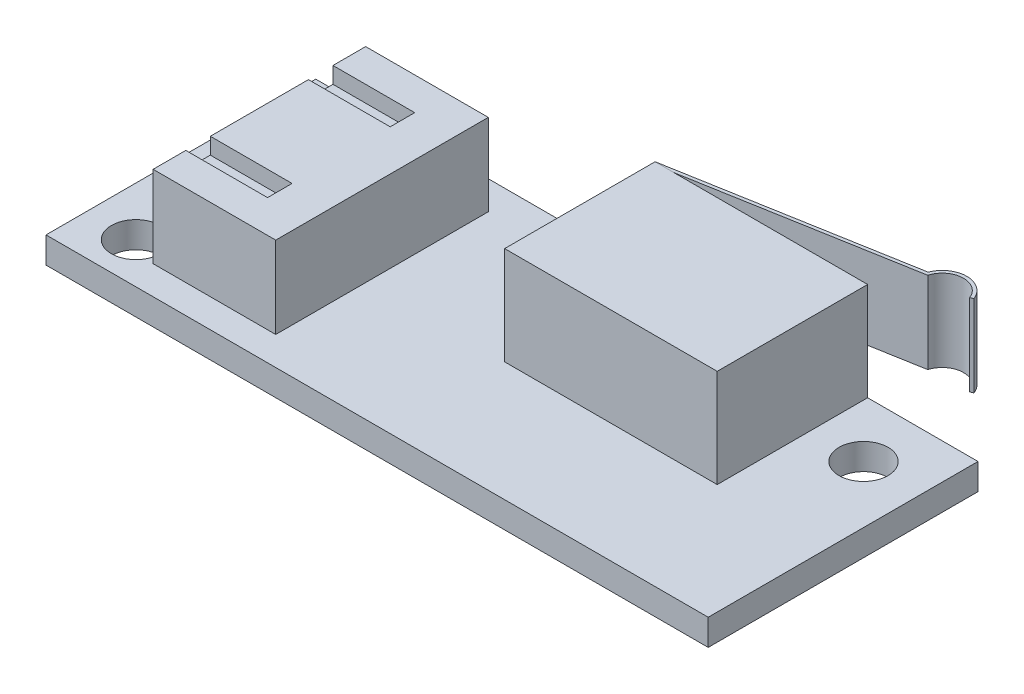
from build123d import *

# Parameters (mm, degrees)
SKETCH1_W           = 40.5
SKETCH1_H           = 16.5
SKETCH1_R           = 1.5
BOSS_EXTRUDE1_DEPTH = 1.6
SKETCH2_W           = 13
SKETCH2_H           = 9.2
BOSS_EXTRUDE2_DEPTH = 6
SKETCH3_W           = 7.5
SKETCH3_H           = 13
BOSS_EXTRUDE3_DEPTH = 5
SKETCH4_W           = 5
SKETCH4_H           = 1.5
CUT_EXTRUDE1_DEPTH  = 1
EXTRUDE_THIN1_DEPTH = 5


with BuildPart() as part:
    # Sketch1 → Boss-Extrude1 (new body)
    with BuildSketch(Plane(origin=(0, 0, 0), x_dir=(1, 0, 0), z_dir=(0, 1, 0))):
        Rectangle(SKETCH1_W, SKETCH1_H)
        with Locations((-17.25, -5.75)):
            Circle(SKETCH1_R, mode=Mode.SUBTRACT)
        with Locations((-17.25, 4.75)):
            Circle(SKETCH1_R, mode=Mode.SUBTRACT)
        with Locations((-2.25, 4.75)):
            Circle(SKETCH1_R, mode=Mode.SUBTRACT)
        with Locations((16.75, 4.75)):
            Circle(SKETCH1_R, mode=Mode.SUBTRACT)
    extrude(amount=BOSS_EXTRUDE1_DEPTH)


with BuildPart() as body_2:
    # Sketch2 → Boss-Extrude2 (new body)
    with BuildSketch(Plane(origin=(0, 1.6, 0), x_dir=(1, 0, 0), z_dir=(0, 1, 0))):
        with Locations((7, 3.65)):
            Rectangle(SKETCH2_W, SKETCH2_H)
    extrude(amount=BOSS_EXTRUDE2_DEPTH)


with BuildPart() as body_3:
    # Sketch3 → Boss-Extrude3 (new body)
    with BuildSketch(Plane(origin=(0, 1.6, 0), x_dir=(1, 0, 0), z_dir=(0, 1, 0))):
        with Locations((-11.7, 0)):
            Rectangle(SKETCH3_W, SKETCH3_H)
    extrude(amount=BOSS_EXTRUDE3_DEPTH)

    # Sketch4 → Cut-Extrude1 (cut)
    with BuildSketch(Plane(origin=(0, 6.6, 0), x_dir=(1, 0, 0), z_dir=(0, 1, 0))):
        with Locations((-12.95, 3.75)):
            Rectangle(SKETCH4_W, SKETCH4_H)
        with Locations((-12.95, -3.75)):
            Rectangle(SKETCH4_W, SKETCH4_H)
    extrude(amount=-CUT_EXTRUDE1_DEPTH, mode=Mode.SUBTRACT)


with BuildPart() as body_4:
    # Sketch5 → Extrude-Thin1 (new body)
    with BuildSketch(Plane(origin=(0, 7.6, 0), x_dir=(1, 0, 0), z_dir=(0, 1, 0))):
        with BuildLine():
            Line((0.5, 8.25), (14.7, 10.753843126))
            ThreePointArc((14.7, 10.753843126), (16.1, 11.715326645), (17.5, 10.753843126))
            Line((17.5, 10.753843126), (17.313333333, 10.682040929))
            ThreePointArc((17.313333333, 10.682040929), (16.044827604, 11.514155351), (14.851458229, 10.577463976))
            Line((14.851458229, 10.577463976), (0.534729636, 8.053038449))
            Line((0.534729636, 8.053038449), (0.5, 8.25))
        make_face()
    extrude(amount=-EXTRUDE_THIN1_DEPTH)


solid = Compound([part.part, body_2.part, body_3.part, body_4.part])
